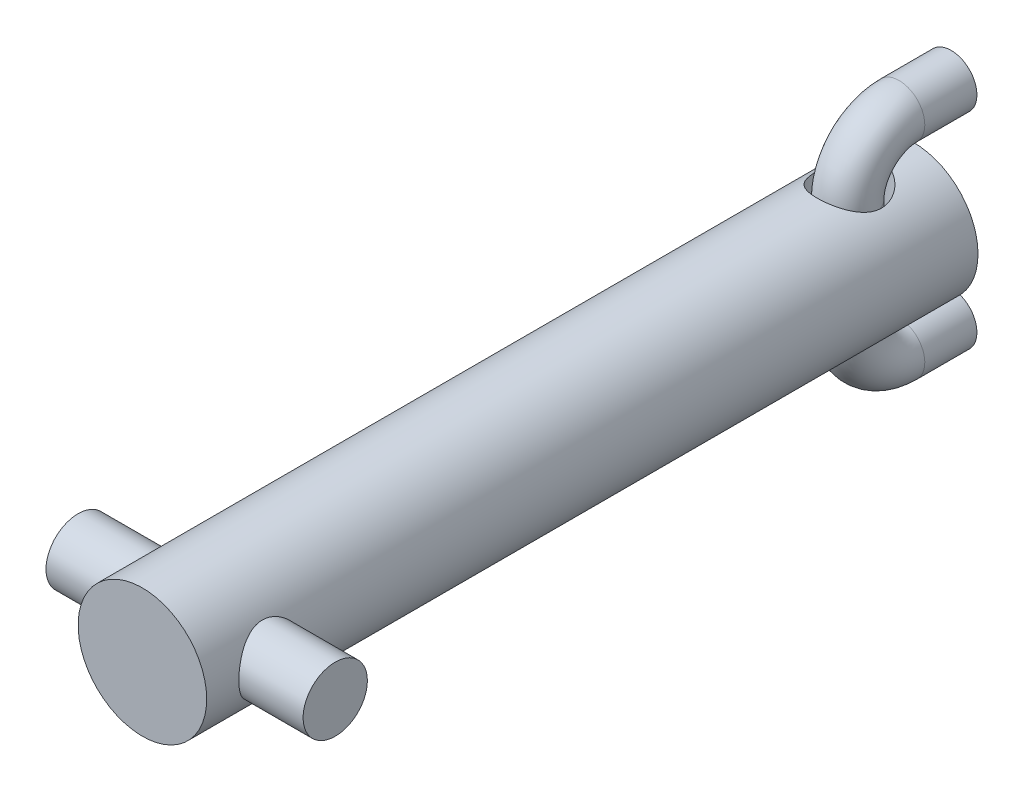
from build123d import *

# Parameters (mm, degrees)
SKETCH1_R           = 3.175
BOSS_EXTRUDE1_DEPTH = 38.1
SKETCH2_R           = 1.5875
CUT_EXTRUDE1_DEPTH  = 15.875
SKETCH3_R           = 1.5875
BOSS_EXTRUDE2_DEPTH = 6.35
SWEEP1_PROFILE_R    = 1.27


with BuildPart() as part:
    # Sketch1 → Boss-Extrude1 (new body)
    with BuildSketch(Plane.XY):
        Circle(SKETCH1_R)
    extrude(amount=BOSS_EXTRUDE1_DEPTH)

    # Sketch2 → Cut-Extrude1 (cut, symmetric)
    with BuildSketch(Plane(origin=(0, 0, 0), x_dir=(1, 0, 0), z_dir=(0, 1, 0))):
        with Locations((0, -3.175)):
            Circle(SKETCH2_R)
    extrude(amount=CUT_EXTRUDE1_DEPTH, both=True, mode=Mode.SUBTRACT)

    # Sketch3 → Boss-Extrude2 (add, symmetric)
    with BuildSketch(Plane(origin=(0, 0, 0), x_dir=(0, 0, -1), z_dir=(1, 0, 0))):
        with Locations((-34.925, 0)):
            Circle(SKETCH3_R)
    extrude(amount=BOSS_EXTRUDE2_DEPTH, both=True)


with BuildPart() as body_2:
    # Sweep1: sweep along a path in Sketch4
    with BuildLine(Plane(origin=(0, 0, 0), x_dir=(0, 0, -1), z_dir=(1, 0, 0))) as sweep1_path:
        Line((1.85035109, 4.922501093), (-0.723036469, 4.922501093))
        ThreePointArc((-0.723036469, 4.922501093), (-2.519087693, 4.178552317), (-3.263036469, 2.382501093))
        Line((-3.263036469, 2.382501093), (-3.263036469, -2.697498907))
        ThreePointArc((-3.263036469, -2.697498907), (-2.519087693, -4.493550132), (-0.723036469, -5.237498907))
        Line((-0.723036469, -5.237498907), (1.85035109, -5.237498907))
    # Sweep1 profile (on start of the path) → Sweep1 (sweep)
    with BuildSketch(Plane(origin=(0, 4.922501093, -1.85035109), x_dir=(1, 0, 0), z_dir=(0, 0, 1))):
        Circle(SWEEP1_PROFILE_R)
    sweep(path=sweep1_path.line)


solid = Compound([part.part, body_2.part])
